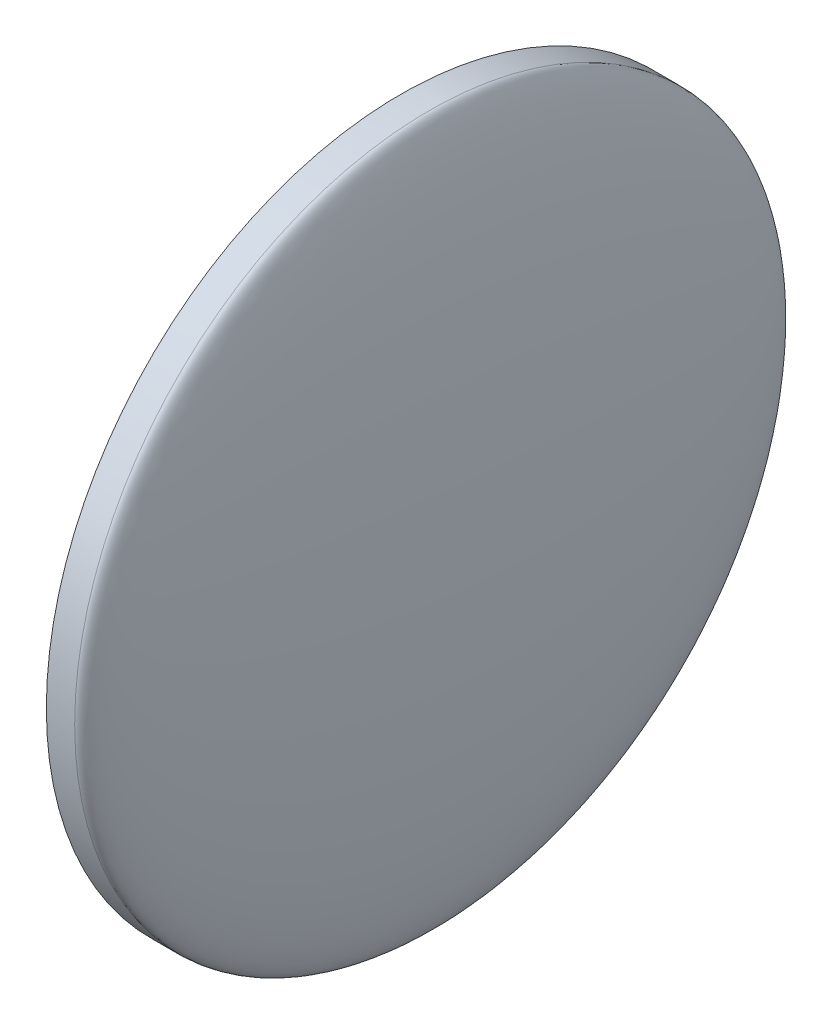
from build123d import *

# Parameters (mm, degrees)
SKETCH1_W = 1
SKETCH1_H = 12.5


with BuildPart() as part:
    # Sketch1 → Revolve1 (revolve)
    with BuildSketch(Plane(origin=(0, 0, 0), x_dir=(1, 0, 0), z_dir=(0, 1, 0))):
        with BuildLine():
            add(Edge.make_bspline(
                [(2.273788661, 0), (2.273788661, 12.5), (1, 12.5)],
                knots=[4.71238898, 4.71238898, 4.71238898, 6.283185307, 6.283185307, 6.283185307], degree=2, weights=[1, 0.707106781, 1]))
            Line((1, 12.5), (1, 0))
            Line((1, 0), (2.273788661, 0))
        make_face()
        with Locations((0.5, 6.25)):
            Rectangle(SKETCH1_W, SKETCH1_H)
    revolve(axis=Axis((0, 0, 0), (1, 0, 0)))


solid = part.part
